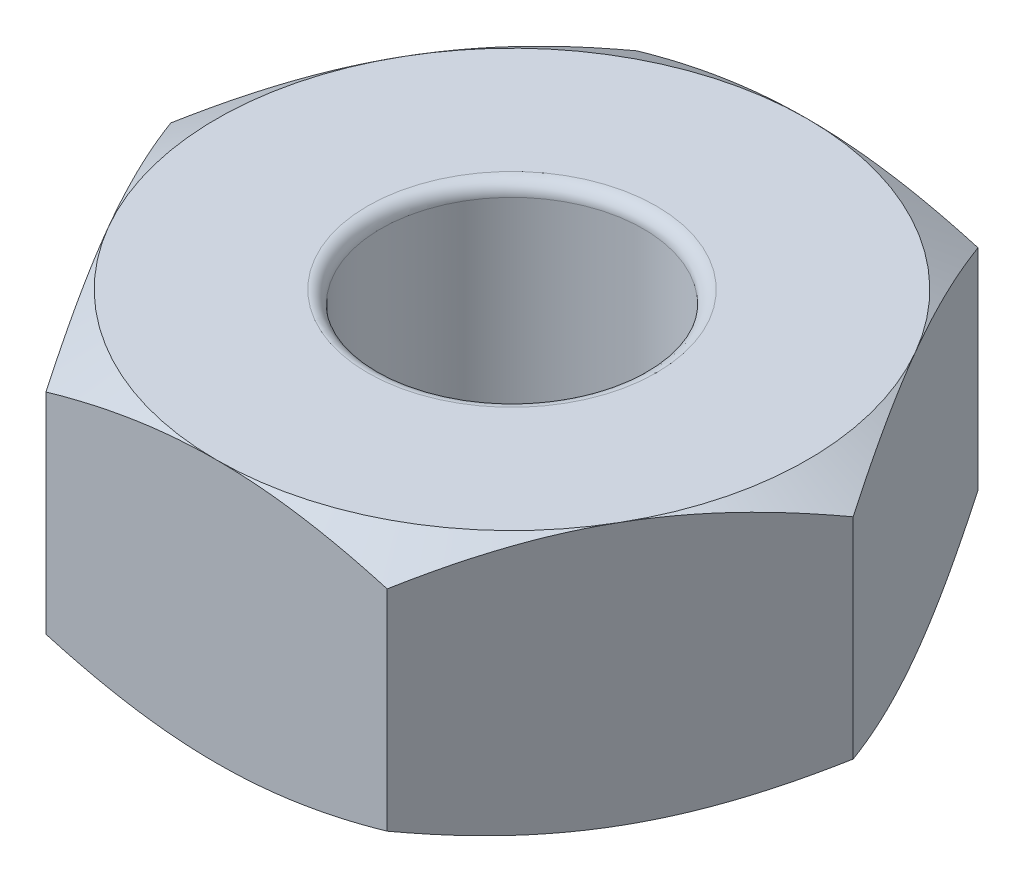
from build123d import *

# Parameters (mm, degrees)
SKETCH1_R           = 1
BOSS_EXTRUDE1_DEPTH = 2
SKETCH2_OUTSIDE_W   = 15.556
SKETCH2_OUTSIDE_H   = 14.86
SKETCH2_OUTSIDE_R   = 2.25
CUT_EXTRUDE2_DEPTH  = 2
CUT_EXTRUDE2_TAPER  = 60
SKETCH3_OUTSIDE_W   = 15.556
SKETCH3_OUTSIDE_H   = 14.86
SKETCH3_OUTSIDE_R   = 2.25
CUT_EXTRUDE3_DEPTH  = 2
CUT_EXTRUDE3_TAPER  = 60
FILLET2_R           = 0.1


with BuildPart() as part:
    # Sketch1 → Boss-Extrude1 (new body)
    with BuildSketch(Plane(origin=(0, 0, 0), x_dir=(1, 0, 0), z_dir=(0, 1, 0))):
        Polygon((2.598076211, 0), (1.299038106, 2.25), (-1.299038106, 2.25), (-2.598076211, 0), (-1.299038106, -2.25), (1.299038106, -2.25), align=None)
        Circle(SKETCH1_R, mode=Mode.SUBTRACT)
    extrude(amount=BOSS_EXTRUDE1_DEPTH)

    # Sketch2 outside → Cut-Extrude2 (cut)
    with BuildSketch(Plane(origin=(0, 0, 0), x_dir=(1, 0, 0), z_dir=(0, 1, 0))):
        Rectangle(SKETCH2_OUTSIDE_W, SKETCH2_OUTSIDE_H)
        Circle(SKETCH2_OUTSIDE_R, mode=Mode.SUBTRACT)
    extrude(amount=CUT_EXTRUDE2_DEPTH, taper=CUT_EXTRUDE2_TAPER, mode=Mode.SUBTRACT)

    # Sketch3 outside → Cut-Extrude3 (cut)
    with BuildSketch(Plane(origin=(0, 2, 0), x_dir=(1, 0, 0), z_dir=(0, 1, 0))):
        Rectangle(SKETCH3_OUTSIDE_W, SKETCH3_OUTSIDE_H)
        Circle(SKETCH3_OUTSIDE_R, mode=Mode.SUBTRACT)
    extrude(amount=-CUT_EXTRUDE3_DEPTH, taper=CUT_EXTRUDE3_TAPER, mode=Mode.SUBTRACT)

    # Fillet2
    fillet2_edges = [part.edges().sort_by_distance(p)[0] for p in [
        (-1, 0, 0),
        (-1, 2, 0),
    ]]
    fillet(fillet2_edges, radius=FILLET2_R)


solid = part.part
